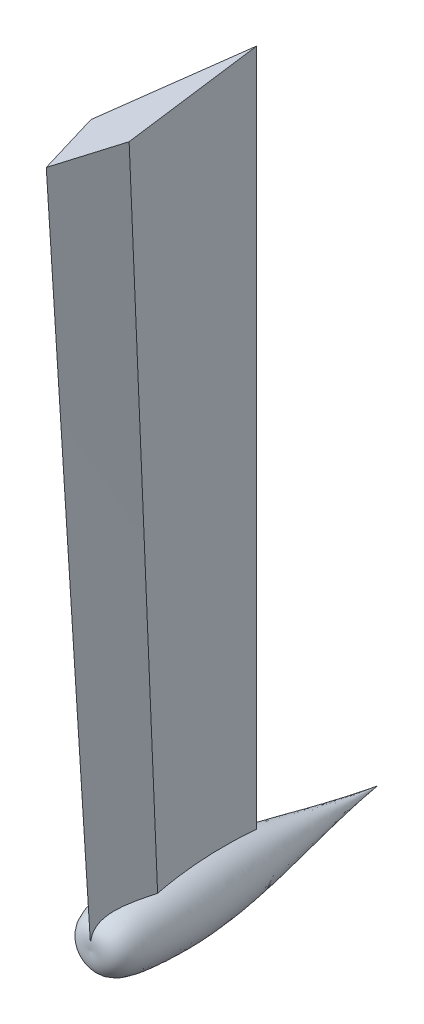
from build123d import *


with BuildPart() as part:
    # Sketch1 → Loft1 section 0
    with BuildSketch(Plane(origin=(0, 0, 0), x_dir=(1, 0, 0), z_dir=(0, 1, 0))):
        Polygon((0, -330), (30, -230), (0, 0), (-30, -230), align=None)
    # Sketch2 → Loft1 section 1
    with BuildSketch(Plane(origin=(0, -1100, 0), x_dir=(1, 0, 0), z_dir=(0, 1, 0))):
        Polygon((0, 0), (20, -173.3333), (0, -260), (-20, -173.3333), align=None)
    loft()

    # Sketch5 → Revolve1 (revolve)
    with BuildSketch(Plane(origin=(0, -1100, 0), x_dir=(1, 0, 0), z_dir=(0, 1, 0))):
        with BuildLine():
            Line((0, -260), (0, 190))
            add(Edge.make_bspline(
                [(0, -260), (41.012814788, -265.650566116), (71.999788311, -83.728725686), (18.703258949, 55.477334844), (0, 190)],
                knots=[0, 0, 0, 0, 0.181249159, 1, 1, 1, 1], degree=3))
        make_face()
    revolve(axis=Axis((0, -1100, 260), (0, 0, -1)))


solid = part.part
